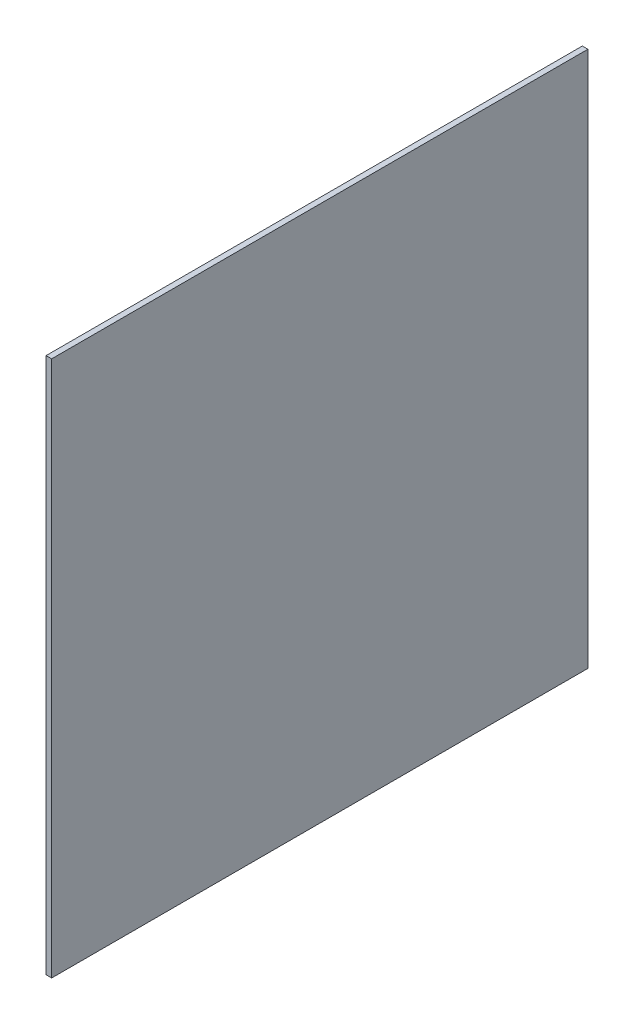
from build123d import *

# Parameters (mm, degrees)
SKETCH1_W           = 304.8
SKETCH1_H           = 304.8
BOSS_EXTRUDE1_DEPTH = 1.5875


with BuildPart() as part:
    # Sketch1 → Boss-Extrude1 (new body, symmetric)
    with BuildSketch(Plane(origin=(0, 0, 0), x_dir=(0, 0, -1), z_dir=(1, 0, 0))):
        Rectangle(SKETCH1_W, SKETCH1_H)
    extrude(amount=BOSS_EXTRUDE1_DEPTH, both=True)


solid = part.part
